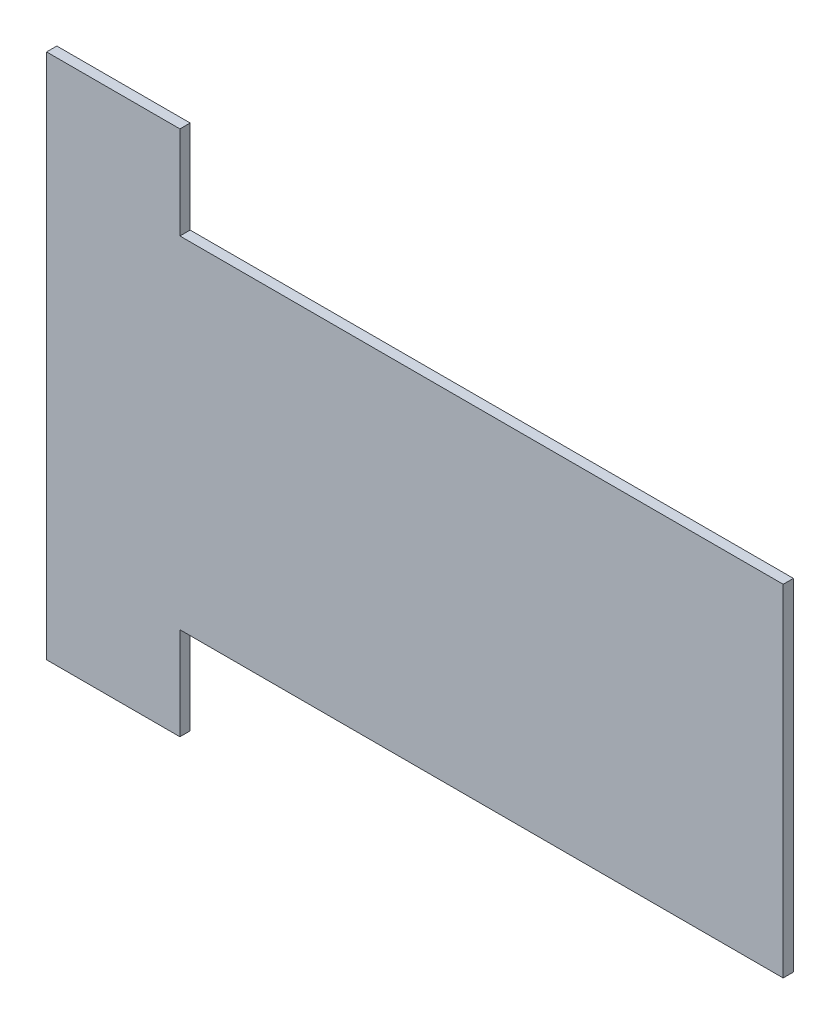
from build123d import *

# Parameters (mm, degrees)
BOSS_EXTRUDE1_DEPTH = 33.45


with BuildPart() as part:
    # Sketch1 → Boss-Extrude1 (new body)
    with BuildSketch(Plane.XY):
        Polygon((218, -557.5), (218, -860.775), (-218, -860.775), (-218, 860.775), (218, 860.775), (218, 557.5), (2190.65, 557.5), (2190.65, -557.5), align=None)
    extrude(amount=BOSS_EXTRUDE1_DEPTH)


solid = part.part
